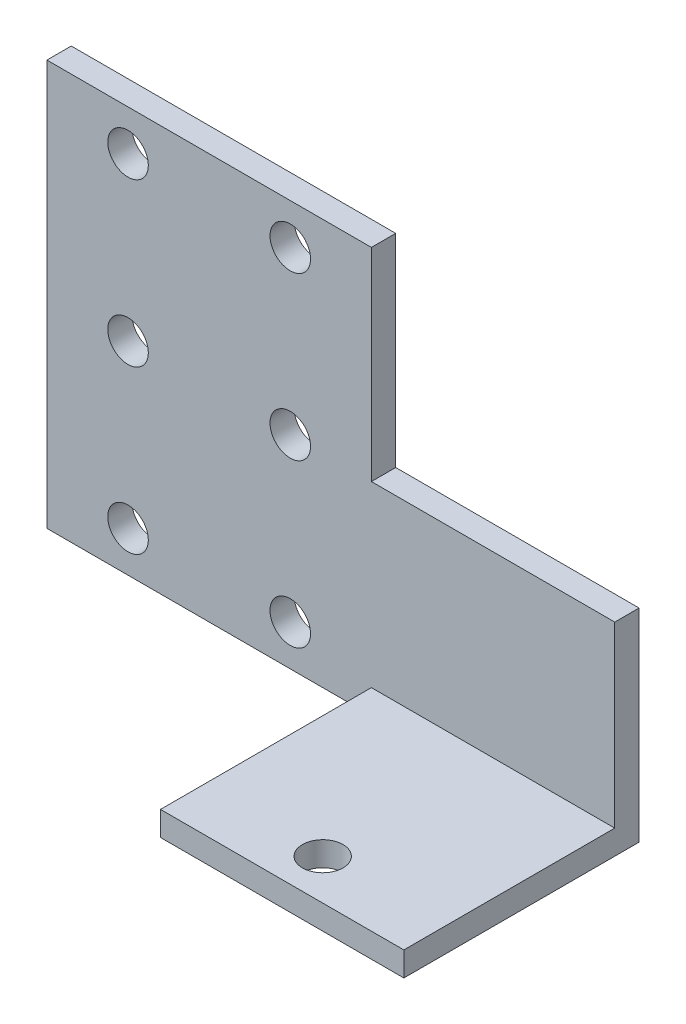
from build123d import *

# Parameters (mm, degrees)
SKETCH1_W               = 40
SKETCH1_H               = 50
SKETCH1_R               = 2.5
BOSS_EXTRUDE1_DEPTH     = 3
BOSS_EXTRUDE2_DEPTH     = 30
SKETCH4_R               = 2.5
CUT_EXTRUDE2_DEPTH      = 48
CUT_EXTRUDE2_DEPTH_BACK = 4


with BuildPart() as part:
    # Sketch1 → Boss-Extrude1 (new body)
    with BuildSketch(Plane.XY):
        with Locations((20, 25)):
            Rectangle(SKETCH1_W, SKETCH1_H)
        with Locations((30, 45)):
            Circle(SKETCH1_R, mode=Mode.SUBTRACT)
        with Locations((10, 45)):
            Circle(SKETCH1_R, mode=Mode.SUBTRACT)
        with Locations((10, 25)):
            Circle(SKETCH1_R, mode=Mode.SUBTRACT)
        with Locations((10, 5)):
            Circle(SKETCH1_R, mode=Mode.SUBTRACT)
        with Locations((30, 25)):
            Circle(SKETCH1_R, mode=Mode.SUBTRACT)
        with Locations((30, 5)):
            Circle(SKETCH1_R, mode=Mode.SUBTRACT)
    extrude(amount=BOSS_EXTRUDE1_DEPTH)

    # Sketch2 → Boss-Extrude2 (add)
    with BuildSketch(Plane(origin=(40, 0, 0), x_dir=(0, 0, -1), z_dir=(1, 0, 0))):
        Polygon((0, 0), (-29, 0), (-29, 3), (-3, 3), (-3, 25), (0, 25), align=None)
    extrude(amount=BOSS_EXTRUDE2_DEPTH)

    # Sketch4 → Cut-Extrude2 (cut, two sides)
    with BuildSketch(Plane(origin=(0, 3, 0), x_dir=(1, 0, 0), z_dir=(0, 1, 0))) as cut_extrude2_sk:
        with Locations((55, -24)):
            Circle(SKETCH4_R)
    extrude(amount=CUT_EXTRUDE2_DEPTH, mode=Mode.SUBTRACT)
    extrude(cut_extrude2_sk.sketch, amount=-CUT_EXTRUDE2_DEPTH_BACK, mode=Mode.SUBTRACT)


solid = part.part
